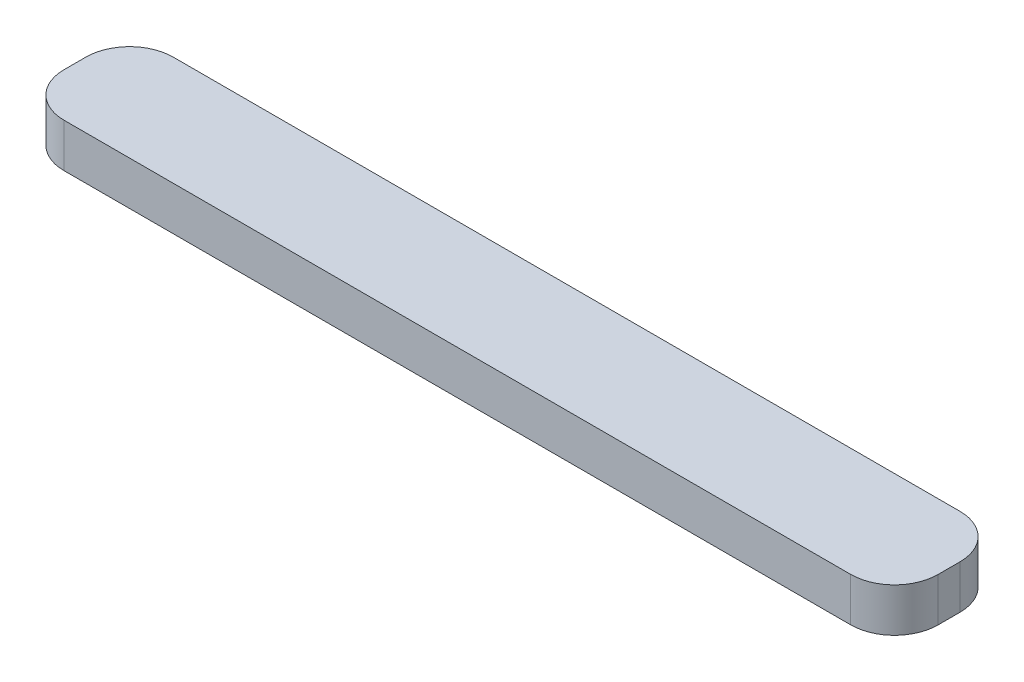
from build123d import *

# Parameters (mm, degrees)
BOSS_EXTRUDE1_DEPTH = 2


with BuildPart() as part:
    # Sketch1 → Boss-Extrude1 (new body)
    with BuildSketch(Plane(origin=(0, 0, 0), x_dir=(1, 0, 0), z_dir=(0, 1, 0))):
        with BuildLine():
            Line((-18, 2.5), (18, 2.5))
            ThreePointArc((18, 2.5), (19.414213562, 1.914213562), (20, 0.5))
            Line((20, 0.5), (20, -0.5))
            ThreePointArc((20, -0.5), (19.414213562, -1.914213562), (18, -2.5))
            Line((18, -2.5), (-18, -2.5))
            ThreePointArc((-18, -2.5), (-19.414213562, -1.914213562), (-20, -0.5))
            Line((-20, -0.5), (-20, 0.5))
            ThreePointArc((-20, 0.5), (-19.414213562, 1.914213562), (-18, 2.5))
        make_face()
    extrude(amount=BOSS_EXTRUDE1_DEPTH)


solid = part.part
